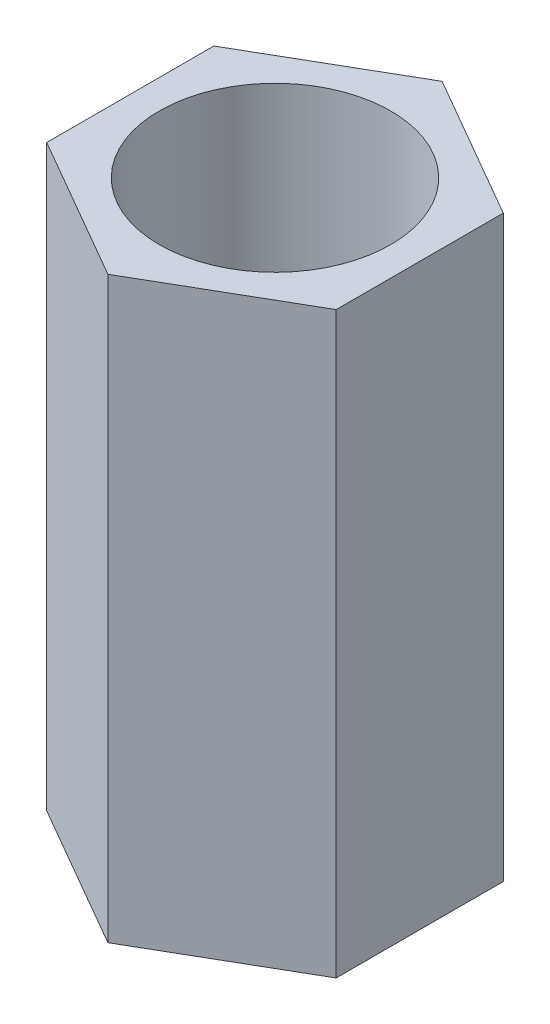
from build123d import *

# Parameters (mm, degrees)
SKETCH1_R           = 2
BOSS_EXTRUDE1_DEPTH = 10


with BuildPart() as part:
    # Sketch1 → Boss-Extrude1 (new body)
    with BuildSketch(Plane(origin=(0, 0, 0), x_dir=(1, 0, 0), z_dir=(0, 1, 0))):
        Polygon((0, 2.886751346), (-2.5, 1.443375673), (-2.5, -1.443375673), (0, -2.886751346), (2.5, -1.443375673), (2.5, 1.443375673), align=None)
        Circle(SKETCH1_R, mode=Mode.SUBTRACT)
    extrude(amount=BOSS_EXTRUDE1_DEPTH)


solid = part.part
